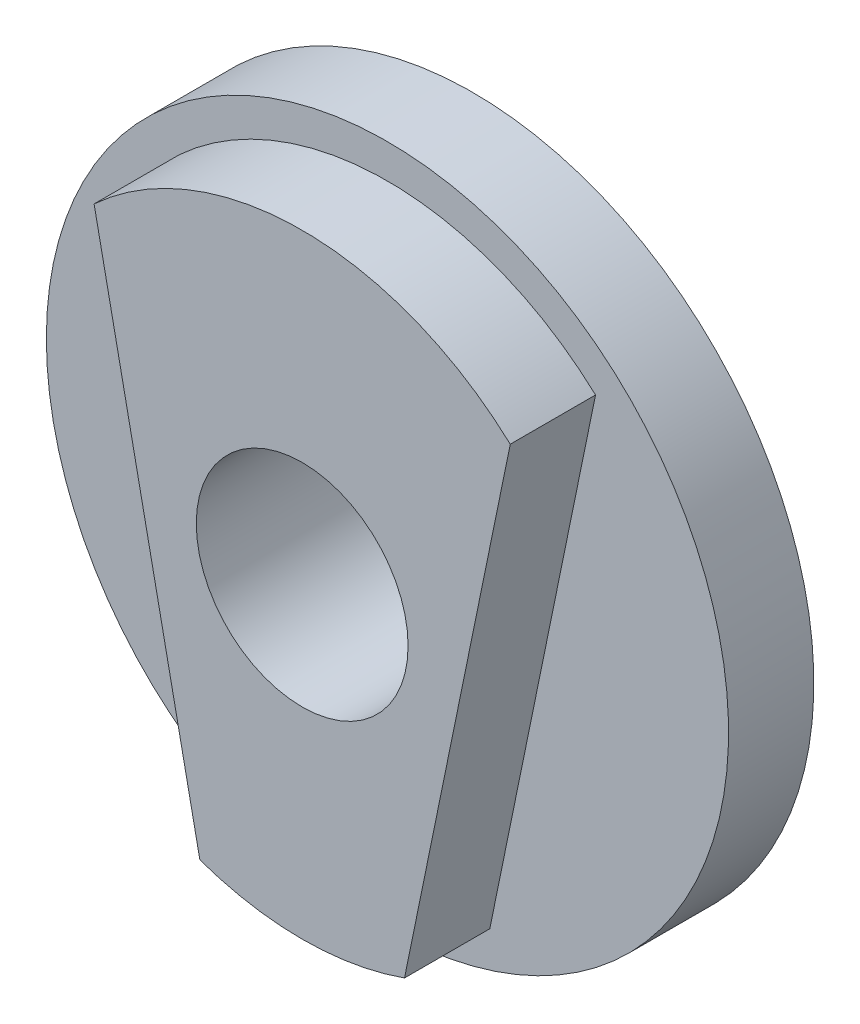
from build123d import *

# Parameters (mm, degrees)
SKETCH1_W           = 1
SKETCH1_H           = 0.25
BOSS_EXTRUDE1_DEPTH = 0.25
CUT_EXTRUDE1_REACH  = 2.675
SKETCH3_R           = 0.3105


with BuildPart() as part:
    # Sketch1 → Revolve1 (revolve)
    with BuildSketch(Plane.XZ):
        with Locations((0.5, 0.3)):
            Rectangle(SKETCH1_W, SKETCH1_H)
    revolve(axis=Axis((0, 0, 0.425), (0, 0, -1)))

    # Sketch2 → Boss-Extrude1 (add)
    with BuildSketch(Plane.XY.offset(0.425)):
        with BuildLine():
            Line((0.610011397, 0.661729625), (0.3, -0.848528137))
            ThreePointArc((0.3, -0.848528137), (0, -0.9), (-0.3, -0.848528137))
            Line((-0.3, -0.848528137), (-0.610011397, 0.661729625))
            ThreePointArc((-0.610011397, 0.661729625), (0, 0.9), (0.610011397, 0.661729625))
        make_face()
    extrude(amount=BOSS_EXTRUDE1_DEPTH)

    # Sketch3 → Cut-Extrude1 (cut, up to next)
    with BuildSketch(Plane.XY, mode=Mode.PRIVATE) as cut_extrude1_sk1:
        Circle(SKETCH3_R)
    cut_extrude1_tool1 = extrude(cut_extrude1_sk1.sketch, amount=CUT_EXTRUDE1_REACH, mode=Mode.PRIVATE) & part.part
    add(cut_extrude1_tool1.solids().sort_by_distance((0, 0, 0))[0], mode=Mode.SUBTRACT)


solid = part.part
